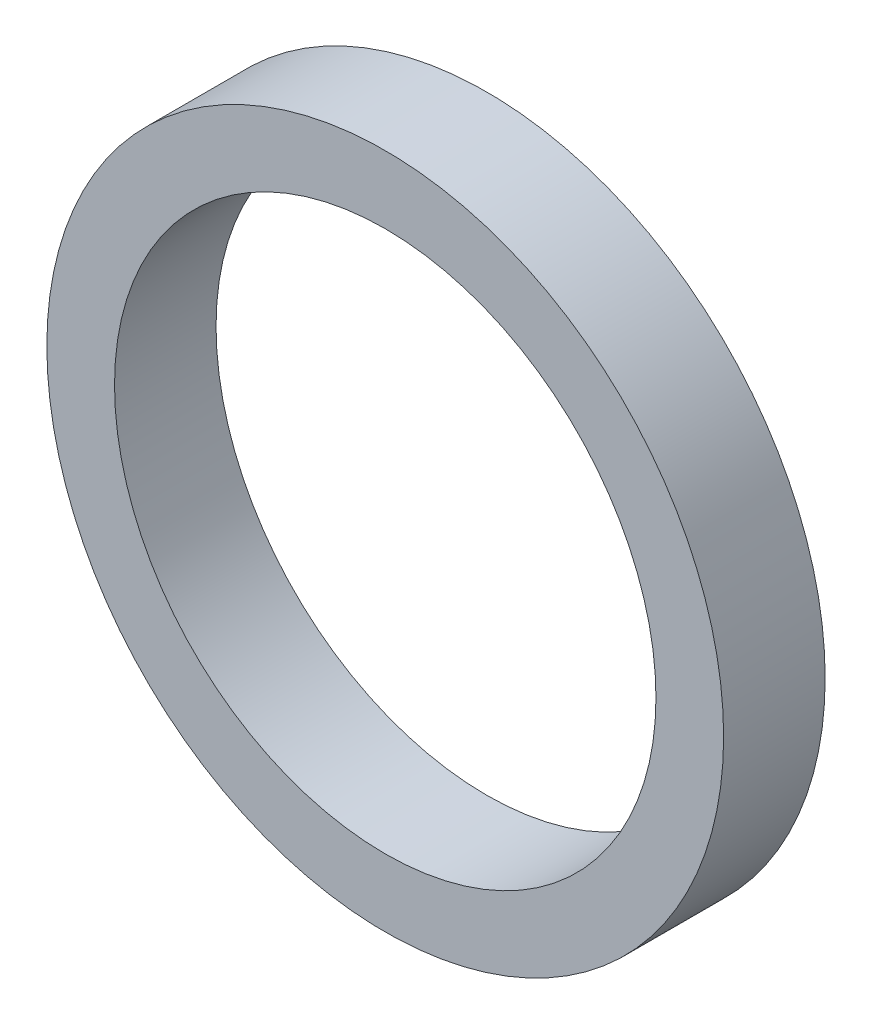
from build123d import *

# Parameters (mm, degrees)
SKETCH1_R           = 10
SKETCH1_R_2         = 8
BOSS_EXTRUDE1_DEPTH = 3


with BuildPart() as part:
    # Sketch1 → Boss-Extrude1 (new body)
    with BuildSketch(Plane.XY):
        Circle(SKETCH1_R)
        Circle(SKETCH1_R_2, mode=Mode.SUBTRACT)
    extrude(amount=BOSS_EXTRUDE1_DEPTH)


solid = part.part
